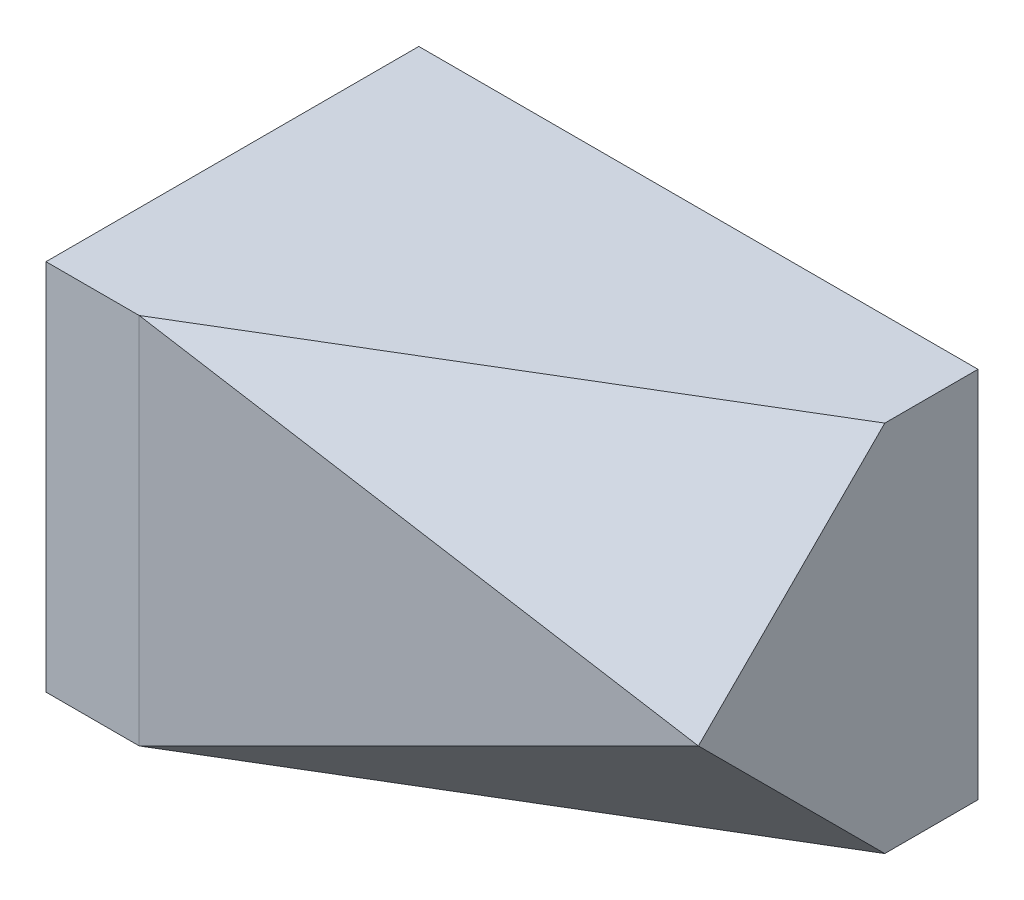
from build123d import *

# Parameters (mm, degrees)
EXTRUDE_1_DEPTH     = 20
SKETCH_4_W          = 39.68109217
SKETCH_4_H          = 19.592945183
CUT_EXTRUDE_1_DEPTH = 20
SKETCH_7_W          = 132.193091595
SKETCH_7_H          = 30.201739996
CUT_EXTRUDE_2_DEPTH = 20
SCALE_1_SCALE       = 0.2


with BuildPart() as part:
    # 草圖1 → 填料-伸長1 (new body)
    with BuildSketch(Plane(origin=(0, 0, 0), x_dir=(1, 0, 0), z_dir=(0, 1, 0))):
        Polygon((15, -5), (-10, -10), (-15, -10), (-15, 10), (15, 10), align=None)
    extrude(amount=EXTRUDE_1_DEPTH)

    # 草圖4 → 除料-伸長1 (cut)
    with BuildSketch(Plane(origin=(6.101694915, 10.169491525, 10.169491525), x_dir=(0.920574618, -0.276172385, -0.276172385), z_dir=(0.390566733, 0.650944555, 0.650944555))):
        with Locations((1.579314275, 10.72678571)):
            Rectangle(SKETCH_4_W, SKETCH_4_H)
    extrude(amount=CUT_EXTRUDE_1_DEPTH, mode=Mode.SUBTRACT)

    # 草圖7 → 除料-伸長2 (cut)
    with BuildSketch(Plane(origin=(1.016949153, -1.694915254, 1.694915254), x_dir=(-0.920574618, -0.276172385, 0.276172385), z_dir=(-0.390566733, 0.650944555, -0.650944555))):
        with Locations((9.754035329, 10.9182289)):
            Rectangle(SKETCH_7_W, SKETCH_7_H)
    extrude(amount=-CUT_EXTRUDE_2_DEPTH, mode=Mode.SUBTRACT)


with BuildPart() as part_1:
    # 縮放比例1: scaled about (-1.575630252, 10, -1.365546218)
    add(part.part.scale(SCALE_1_SCALE).moved(Location((-1.260504202, 8, -1.092436974))))


solid = part_1.part
